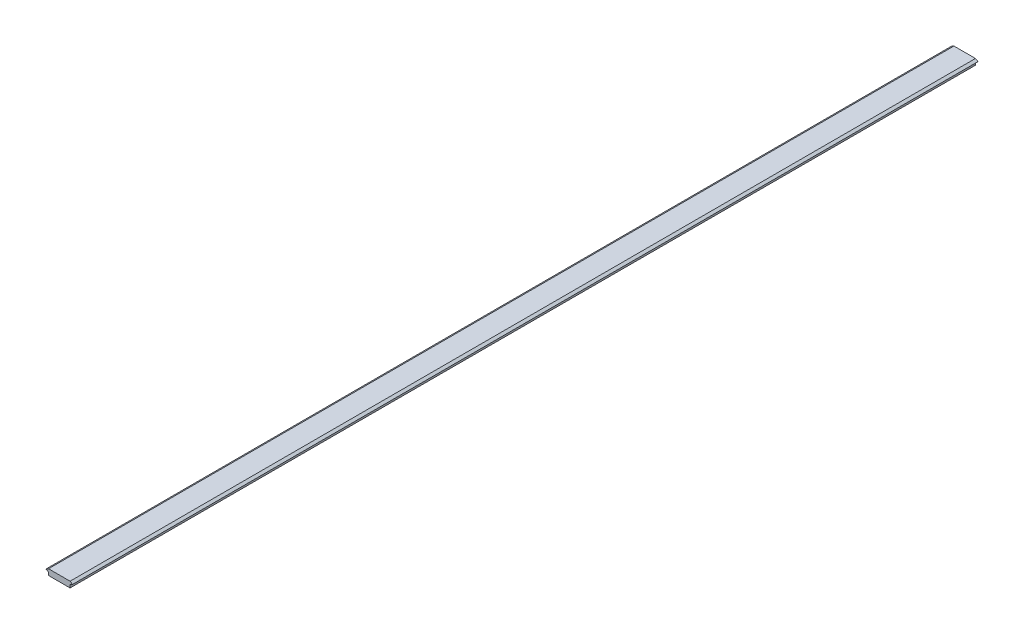
from build123d import *

# Parameters (mm, degrees)
BOSS_EXTRUDE1_DEPTH = 925


with BuildPart() as part:
    # Sketch1 → Boss-Extrude1 (new body)
    with BuildSketch(Plane.XY):
        Polygon((0, 0), (22, 0), (24.598076211, -1.5), (22, -3), (22, -6), (0, -6), (0, -3), (-2.598076211, -1.5), align=None)
    extrude(amount=BOSS_EXTRUDE1_DEPTH)


solid = part.part
